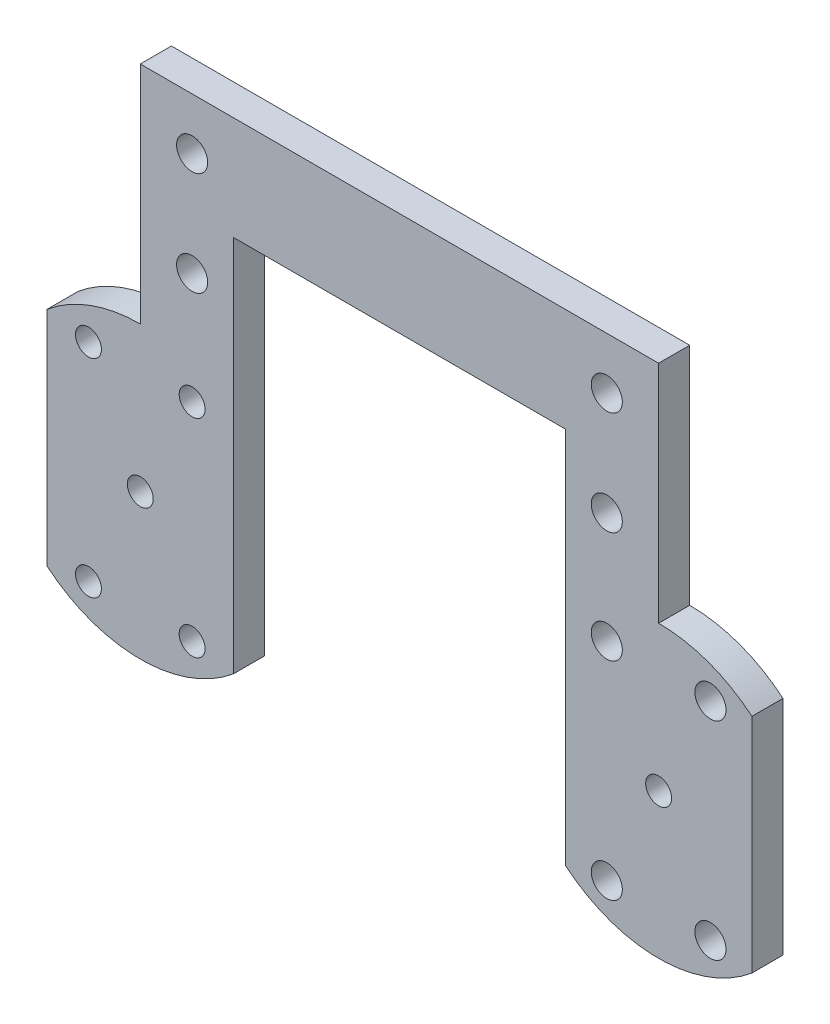
from build123d import *

# Parameters (mm, degrees)
SKETCH1_R           = 1.25
SKETCH1_R_2         = 1.5
BOSS_EXTRUDE1_DEPTH = 3
SKETCH2_R           = 1.5
BOSS_EXTRUDE2_DEPTH = 3
SKETCH3_W           = 32
SKETCH3_H           = 21.44761059
CUT_EXTRUDE1_DEPTH  = 4


with BuildPart() as part:
    # Sketch1 → Boss-Extrude1 (new body)
    with BuildSketch(Plane.XY):
        with BuildLine():
            Line((-9, 10.723805295), (-9, -10.723805295))
            ThreePointArc((-9, -10.723805295), (0, -14), (9, -10.723805295))
            Line((9, -10.723805295), (41, -10.723805295))
            ThreePointArc((41, -10.723805295), (50, -14), (59, -10.723805295))
            Line((59, -10.723805295), (59, 10.723805295))
            ThreePointArc((59, 10.723805295), (50, 14), (41, 10.723805295))
            Line((41, 10.723805295), (9, 10.723805295))
            ThreePointArc((9, 10.723805295), (0, 14), (-9, 10.723805295))
        make_face()
        Circle(SKETCH1_R, mode=Mode.SUBTRACT)
        with Locations((-5, 10)):
            Circle(SKETCH1_R, mode=Mode.SUBTRACT)
        with Locations((5, 10)):
            Circle(SKETCH1_R, mode=Mode.SUBTRACT)
        with Locations((-5, -10)):
            Circle(SKETCH1_R, mode=Mode.SUBTRACT)
        with Locations((5, -10)):
            Circle(SKETCH1_R, mode=Mode.SUBTRACT)
        with Locations((50, 0)):
            Circle(SKETCH1_R, mode=Mode.SUBTRACT)
        with Locations((45, 10)):
            Circle(SKETCH1_R_2, mode=Mode.SUBTRACT)
        with Locations((55, 10)):
            Circle(SKETCH1_R_2, mode=Mode.SUBTRACT)
        with Locations((45, -10)):
            Circle(SKETCH1_R_2, mode=Mode.SUBTRACT)
        with Locations((55, -10)):
            Circle(SKETCH1_R_2, mode=Mode.SUBTRACT)
        with Locations((25, 0)):
            Circle(SKETCH1_R, mode=Mode.SUBTRACT)
        with Locations((25, 5)):
            Circle(SKETCH1_R, mode=Mode.SUBTRACT)
        with Locations((25, -5)):
            Circle(SKETCH1_R, mode=Mode.SUBTRACT)
        with Locations((35, 0)):
            Circle(SKETCH1_R, mode=Mode.SUBTRACT)
        with Locations((15, 0)):
            Circle(SKETCH1_R, mode=Mode.SUBTRACT)
        with Locations((35, 5)):
            Circle(SKETCH1_R, mode=Mode.SUBTRACT)
        with Locations((35, -5)):
            Circle(SKETCH1_R, mode=Mode.SUBTRACT)
        with Locations((15, -5)):
            Circle(SKETCH1_R, mode=Mode.SUBTRACT)
        with Locations((15, 5)):
            Circle(SKETCH1_R, mode=Mode.SUBTRACT)
    extrude(amount=BOSS_EXTRUDE1_DEPTH)

    # Sketch2 → Boss-Extrude2 (add)
    with BuildSketch(Plane.XY.offset(3)):
        with BuildLine():
            Line((0, 14), (0, 35.723805295))
            Line((0, 35.723805295), (50, 35.723805295))
            Line((50, 35.723805295), (50, 14))
            ThreePointArc((50, 14), (45.21112091, 13.155479355), (41, 10.723805295))
            Line((41, 10.723805295), (41, 25.723805295))
            Line((41, 25.723805295), (9, 25.723805295))
            Line((9, 25.723805295), (9, 10.723805295))
            ThreePointArc((9, 10.723805295), (4.78887909, 13.155479355), (0, 14))
        make_face()
        with Locations((5, 30.723805295)):
            Circle(SKETCH2_R, mode=Mode.SUBTRACT)
        with Locations((45, 30.723805295)):
            Circle(SKETCH2_R, mode=Mode.SUBTRACT)
        with Locations((45, 20.723805295)):
            Circle(SKETCH2_R, mode=Mode.SUBTRACT)
        with Locations((5, 20.723805295)):
            Circle(SKETCH2_R, mode=Mode.SUBTRACT)
    extrude(amount=-BOSS_EXTRUDE2_DEPTH)

    # Sketch3 → Cut-Extrude1 (cut, through all)
    with BuildSketch(Plane.XY.offset(3)):
        with Locations((25, 0)):
            Rectangle(SKETCH3_W, SKETCH3_H)
    extrude(amount=-CUT_EXTRUDE1_DEPTH, mode=Mode.SUBTRACT)


solid = part.part
